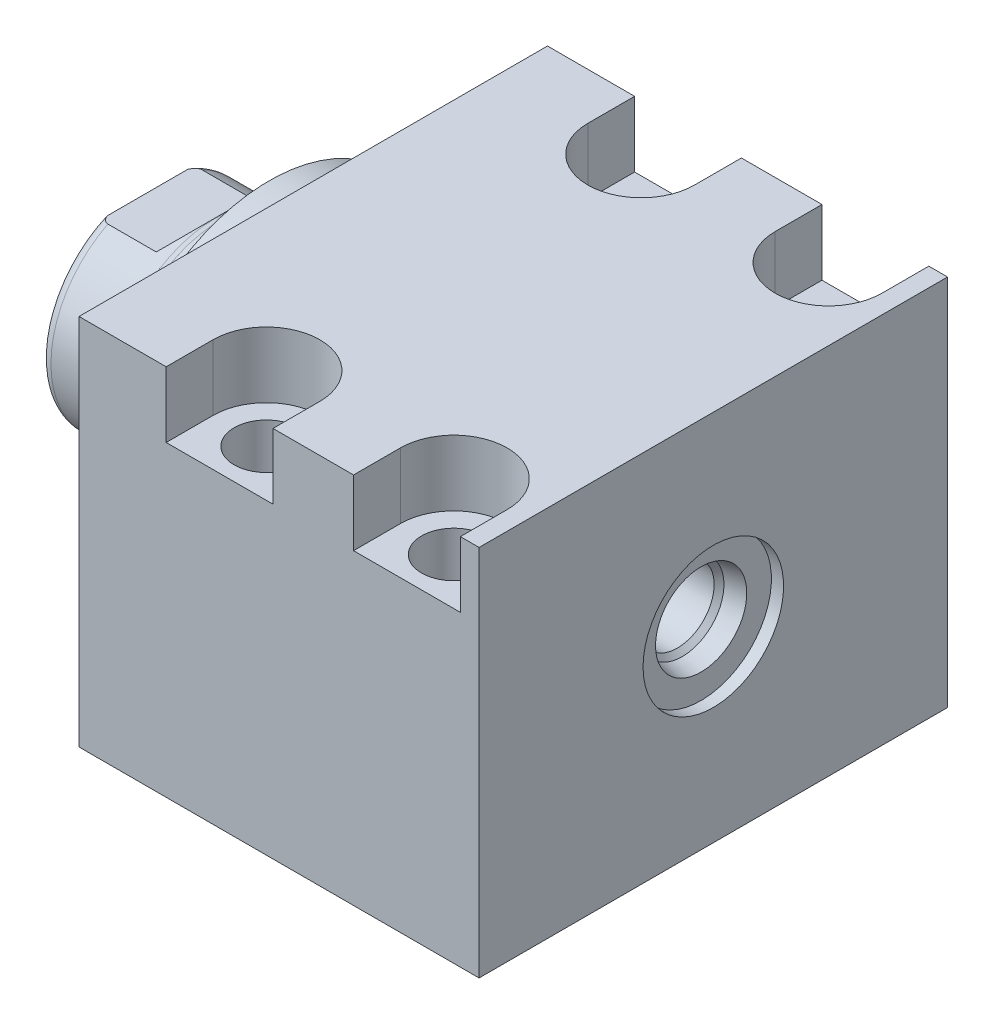
from build123d import *

# Parameters (mm, degrees)
SKETCH1_W          = 63.5
SKETCH1_H          = 50.546
EXTRUDE1_DEPTH     = 54.229
SKETCH5_R          = 22.225
EXTRUDE2_DEPTH     = 5.969
SKETCH6_W          = 14.2875
SKETCH6_H          = 16.51
CUT_EXTRUDE4_DEPTH = 30.48
HOLE2_D            = 8.7376
HOLE2_DEPTH        = 50.546
LPATTERN1_COUNT    = 2
LPATTERN1_PITCH    = 25.4
CUT_EXTRUDE5_DEPTH = 8.89
HOLE3_D            = 3.175
HOLE3_DEPTH        = 9.525
HOLE3_CBORE_D      = 11.3411
HOLE3_CBORE_DEPTH  = 1.4478
HOLE3_TIP          = 0.953866233
HOLE4_D            = 3.175
HOLE4_DEPTH        = 9.525
HOLE4_CBORE_D      = 11.3411
HOLE4_CBORE_DEPTH  = 1.4478
HOLE4_TIP          = 0.953866233
CHAMFER1_SIZE      = 0.635
SKETCH23_R         = 1.4478
LPATTERN3_COUNT    = 2
LPATTERN3_PITCH    = 25.4


with BuildPart() as part:
    # Sketch1 → Extrude1 (new body)
    with BuildSketch(Plane(origin=(0, 0, 0), x_dir=(0, 0, -1), z_dir=(1, 0, 0))):
        with Locations((0, -0.127)):
            Rectangle(SKETCH1_W, SKETCH1_H)
    extrude(amount=EXTRUDE1_DEPTH)

    # Sketch5 → Extrude2 (add)
    with BuildSketch(Plane.ZY):
        with Locations(Location((0, 0, 0), (0, 0, 180))):  # turned: the seam where the file's is
            Circle(SKETCH5_R)
    extrude(amount=EXTRUDE2_DEPTH)

    # Sketch6 → Revolve1 (revolve)
    with BuildSketch(Plane(origin=(0, 0, 0), x_dir=(0, 0, 1), z_dir=(0, -1, 0))):
        with Locations((-7.14375, 14.224)):
            Rectangle(SKETCH6_W, SKETCH6_H)
    revolve(axis=Axis((5.754582971, 0, 0), (-1, 0, 0)))

    # S2D0001 → Cut-Revolve4 (revolve, cut)
    with BuildSketch(Plane(origin=(-18.511260017, 3.2639, 0), x_dir=(0, 1, 0), z_dir=(0, 0, 1)), mode=Mode.PRIVATE) as cut_revolve4_sk:
        Polygon((2.286, 1.900017728), (2.286, -14.650460017), (-3.2639, -14.650460017), (-3.2639, 3.967739983), (3.4798, 3.967739983), align=None)
    revolve(cut_revolve4_sk.sketch.rotate(Axis((0, 0, 0), (-1, 0, 0)), 90), axis=Axis((0, 0, 0), (-1, 0, 0)), mode=Mode.SUBTRACT)  # turned: the seam where the file's is

    # Sketch8 → Cut-Revolve5 (revolve, cut)
    with BuildSketch(Plane(origin=(0, 0, 0), x_dir=(0, 0, -1), z_dir=(0, 1, 0)), mode=Mode.PRIVATE) as cut_revolve5_sk:
        with BuildLine():
            Line((-14.2875, 12.573), (-14.097, 13.335))
            Line((-14.097, 13.335), (-14.097, 21.463))
            ThreePointArc((-14.097, 21.463), (-13.996678675, 22.006796865), (-13.708922533, 22.479))
            Line((-13.708922533, 22.479), (-14.2875, 22.479))
            Line((-14.2875, 22.479), (-14.2875, 12.573))
        make_face()
    revolve(cut_revolve5_sk.sketch.rotate(Axis((-12.65936, 0, 0), (-1, 0, 0)), 180), axis=Axis((-12.65936, 0, 0), (-1, 0, 0)), mode=Mode.SUBTRACT)  # turned: the seam where the file's is

    # Sketch12 → Cut-Extrude4 (cut, symmetric)
    with BuildSketch(Plane(origin=(0, 0, 0), x_dir=(0, -1, 0), z_dir=(0, 0, -1))):
        Polygon((12.573, 22.479), (12.573, 14.9098), (14.097, 13.3858), (14.097, 22.479), align=None)
        Polygon((-12.573, 22.479), (-12.573, 14.9098), (-14.097, 13.3858), (-14.097, 22.479), align=None)
    extrude(amount=CUT_EXTRUDE4_DEPTH, both=True, mode=Mode.SUBTRACT)

    # Hole2
    with Locations(Plane(origin=(0, 25.146, 0), x_dir=(-1, 0, 0), z_dir=(0, 1, 0))):
        with Locations((-19.05, -25.4), (-19.05, 25.4)):
            hole2 = Hole(HOLE2_D / 2, depth=HOLE2_DEPTH)

    # LPattern1: Hole2 ×2
    with Locations(*[(i * LPATTERN1_PITCH, 0, 0) for i in range(1, LPATTERN1_COUNT)]):
        add(hole2, mode=Mode.SUBTRACT)

    # Sketch18 → Cut-Extrude5 (cut)
    with BuildSketch(Plane(origin=(0, 25.146, 0), x_dir=(1, 0, 0), z_dir=(0, 1, 0))):
        with BuildLine():
            Line((51.689, -31.75), (37.211, -31.75))
            Line((37.211, -31.75), (37.211, -25.4))
            ThreePointArc((37.211, -25.4), (44.45, -18.161), (51.689, -25.4))
            Line((51.689, -25.4), (51.689, -31.75))
        make_face()
        with BuildLine():
            Line((11.811, -25.4), (11.811, -31.75))
            Line((11.811, -31.75), (26.289, -31.75))
            Line((26.289, -31.75), (26.289, -25.4))
            ThreePointArc((26.289, -25.4), (19.05, -18.161), (11.811, -25.4))
        make_face()
        with BuildLine():
            Line((51.689, 25.4), (51.689, 31.75))
            Line((51.689, 31.75), (37.211, 31.75))
            Line((37.211, 31.75), (37.211, 25.4))
            ThreePointArc((37.211, 25.4), (44.45, 18.161), (51.689, 25.4))
        make_face()
        with BuildLine():
            Line((26.289, 31.75), (11.811, 31.75))
            Line((11.811, 31.75), (11.811, 25.4))
            ThreePointArc((11.811, 25.4), (19.05, 18.161), (26.289, 25.4))
            Line((26.289, 25.4), (26.289, 31.75))
        make_face()
    extrude(amount=-CUT_EXTRUDE5_DEPTH, mode=Mode.SUBTRACT)

    # Hole3
    with Locations(Plane.XZ.offset(25.4)):
        with Locations((12.7, 0)):
            CounterBoreHole(HOLE3_D / 2, HOLE3_CBORE_D / 2, HOLE3_CBORE_DEPTH, depth=HOLE3_DEPTH)
            with Locations((0, 0, -(HOLE3_DEPTH + HOLE3_TIP / 2))):  # 118° drill point
                Cone(0, HOLE3_D / 2, HOLE3_TIP, mode=Mode.SUBTRACT)

    # Hole4
    with Locations(Plane.XZ.offset(25.4)):
        with Locations((38.1, 0)):
            CounterBoreHole(HOLE4_D / 2, HOLE4_CBORE_D / 2, HOLE4_CBORE_DEPTH, depth=HOLE4_DEPTH)
            with Locations((0, 0, -(HOLE4_DEPTH + HOLE4_TIP / 2))):  # 118° drill point
                Cone(0, HOLE4_D / 2, HOLE4_TIP, mode=Mode.SUBTRACT)

    # Chamfer1
    chamfer1_edges = [part.edges().sort_by_distance(p)[0] for p in [
        (14.2875, -23.9522, 0),
        (39.6875, -23.9522, 0),
    ]]
    chamfer(chamfer1_edges, length=CHAMFER1_SIZE)

    # Sketch24 → Cut-Revolve6 (revolve, cut)
    with BuildSketch(Plane.XY, mode=Mode.PRIVATE) as cut_revolve6_sk:
        Polygon((54.229, 9.525), (52.578, 9.525), (52.578, 6.1849), (50.0253, 5.642306865), (49.361393135, 4.9784), (37.973, 4.9784), (37.973, 0), (54.229, 0), align=None)
    revolve(cut_revolve6_sk.sketch.rotate(Axis((0, 0, 0), (1, 0, 0)), 270), axis=Axis((0, 0, 0), (1, 0, 0)), mode=Mode.SUBTRACT)  # turned: the seam where the file's is


with BuildPart() as body_2:
    # Sketch23 → Revolve2 (revolve)
    with BuildSketch(Plane.XY, mode=Mode.PRIVATE) as revolve2_sk:
        with Locations((8.47725, -25.4)):
            Circle(SKETCH23_R)
    revolve(revolve2_sk.sketch.rotate(Axis((12.7, -23.9522, 0), (0, 1, 0)), 270), axis=Axis((12.7, -23.9522, 0), (0, 1, 0)))  # turned: the seam where the file's is


with BuildPart() as lpattern3_1:
    # LPattern3: pattern copy
    add(body_2.part.moved(Location(Vector(1, 0, 0) * (1 * LPATTERN3_PITCH))))


solid = Compound([part.part, body_2.part, lpattern3_1.part])
